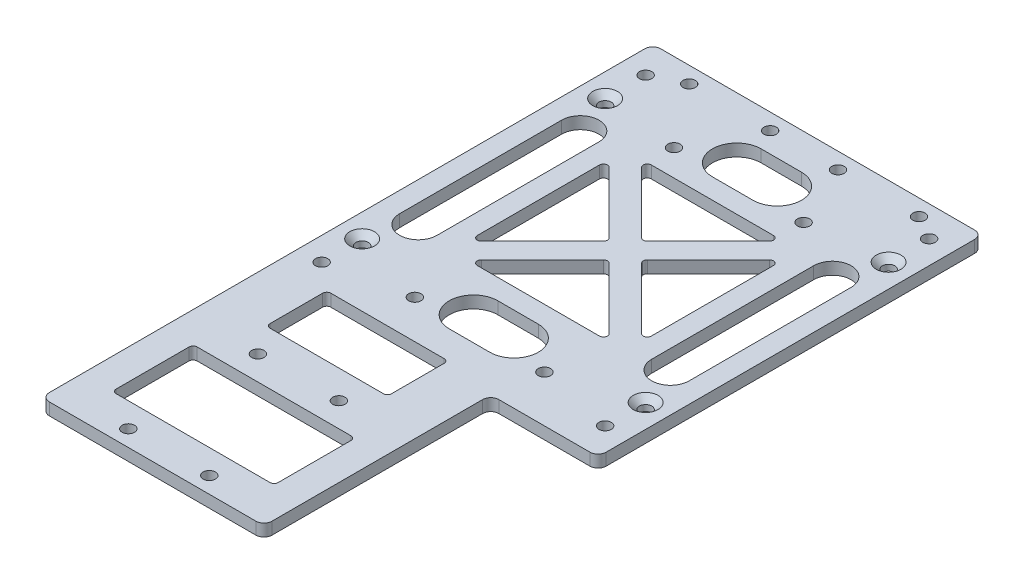
from build123d import *

# Parameters (mm, degrees)
EXTRUDE_1_DEPTH           = 3
SKETCH_2_R                = 1.525
CUT_EXTRUDE_1_DEPTH       = 4
SKETCH_5_W                = 6.5
SKETCH_5_H                = 95
CUT_EXTRUDE_4_DEPTH       = 4
FILLET_3_R                = 2
SKETCH_7_R                = 1.525
CUT_EXTRUDE_6_DEPTH       = 10
SKETCH_10_R               = 1.525
CUT_EXTRUDE_8_DEPTH       = 10
CUT_EXTRUDE_9_DEPTH       = 1
CUT_EXTRUDE_9_DEPTH_BACK  = 4
FILLET_4_R                = 1
SKETCH_15_W               = 40
SKETCH_15_H               = 20
SKETCH_15_W_2             = 30
SKETCH_15_H_2             = 15
CUT_EXTRUDE_10_DEPTH      = 1
CUT_EXTRUDE_10_DEPTH_BACK = 4
FILLET_5_R                = 1
CUT_EXTRUDE_12_DEPTH      = 1
CUT_EXTRUDE_12_DEPTH_BACK = 4
SKETCH_19_R               = 1.525
CUT_EXTRUDE_13_DEPTH      = 10
CUT_EXTRUDE_14_DEPTH      = 10
HOLE_WIZARD_1_D           = 3.05
HOLE_WIZARD_1_DEPTH       = 100
HOLE_WIZARD_1_CSINK_D     = 6.1
HOLE_WIZARD_1_CSINK_ANGLE = 90


with BuildPart() as part:
    # 草图1 → 凸台-拉伸1 (new body)
    with BuildSketch(Plane(origin=(0, 0, 0), x_dir=(1, 0, 0), z_dir=(0, 1, 0))):
        Polygon((33, -55), (33, 0), (33, 40), (-55, 40), (-55, -111), (0, -111), (0, -55), align=None)
    extrude(amount=EXTRUDE_1_DEPTH)

    # 草图2 → 切除-拉伸1 (cut, through all)
    with BuildSketch(Plane(origin=(0, 3, 0), x_dir=(1, 0, 0), z_dir=(0, 1, 0))):
        with Locations((-37.5, -107)):
            Circle(SKETCH_2_R)
        with Locations((-17.5, -107)):
            Circle(SKETCH_2_R)
        with Locations((-37.5, -75)):
            Circle(SKETCH_2_R)
        with Locations((-17.5, -75)):
            Circle(SKETCH_2_R)
        with Locations((-42, 36)):
            Circle(SKETCH_2_R)
        with Locations((-22, 36)):
            Circle(SKETCH_2_R)
        with Locations((-5.25, 36)):
            Circle(SKETCH_2_R)
        with Locations((14.75, 36)):
            Circle(SKETCH_2_R)
    extrude(amount=-CUT_EXTRUDE_1_DEPTH, mode=Mode.SUBTRACT)

    # 草图5 → 切除-拉伸4 (cut, through all)
    with BuildSketch(Plane(origin=(0, 3, 0), x_dir=(1, 0, 0), z_dir=(0, 1, 0))):
        with Locations((29.75, -7.5)):
            Rectangle(SKETCH_5_W, SKETCH_5_H)
    extrude(amount=-CUT_EXTRUDE_4_DEPTH, mode=Mode.SUBTRACT)

    # 圆角3
    fillet_3_edges = [part.edges().sort_by_distance(p)[0] for p in [
        (0, 1.5, 111),
        (-55, 1.5, 111),
        (-55, 1.5, -40),
        (0, 1.5, 55),
        (26.5, 1.5, 55),
        (26.5, 1.5, -40),
    ]]
    fillet(fillet_3_edges, radius=FILLET_3_R)

    # 草图7 → 切除-拉伸6 (cut)
    with BuildSketch(Plane.XZ):
        with Locations((-49.25, 47.5)):
            Circle(SKETCH_7_R)
        with Locations((-49.25, -32.5)):
            Circle(SKETCH_7_R)
        with Locations((20.75, -32.5)):
            Circle(SKETCH_7_R)
        with Locations((20.75, 47.5)):
            Circle(SKETCH_7_R)
    extrude(amount=-CUT_EXTRUDE_6_DEPTH, mode=Mode.SUBTRACT)

    # 草图10 → 切除-拉伸8 (cut)
    with BuildSketch(Plane.XZ):
        with Locations((-30.25, 43.5)):
            Circle(SKETCH_10_R)
        with Locations((1.75, 43.5)):
            Circle(SKETCH_10_R)
        with Locations((-30.25028, -20.4998432)):
            Circle(SKETCH_10_R)
        with Locations((1.75, -20.5)):
            Circle(SKETCH_10_R)
    extrude(amount=-CUT_EXTRUDE_8_DEPTH, mode=Mode.SUBTRACT)

    # 草图14 → 切除-拉伸9 (cut, two sides)
    with BuildSketch(Plane(origin=(0, 3, 0), x_dir=(1, 0, 0), z_dir=(0, 1, 0))) as cut_extrude_9_sk:
        Polygon((-10.25, -7.5), (7.25, 10), (7.25, -25), align=None)
        Polygon((-31.75, 14), (3.25, 14), (-14.25, -3.5), align=None)
        Polygon((-14.25, -11.5), (3.25, -29), (-31.75, -29), align=None)
        Polygon((-18.25, -7.5), (-35.75, -25), (-35.75, 10), align=None)
    extrude(amount=CUT_EXTRUDE_9_DEPTH, mode=Mode.SUBTRACT)
    extrude(cut_extrude_9_sk.sketch, amount=-CUT_EXTRUDE_9_DEPTH_BACK, mode=Mode.SUBTRACT)

    # 圆角4
    fillet_4_edges = [part.edges().sort_by_distance(p)[0] for p in [
        (3.25, 1.5, 29),
        (-31.75, 1.5, 29),
        (-14.25, 1.5, 11.5),
        (7.25, 1.5, -10),
        (7.25, 1.5, 25),
        (-10.25, 1.5, 7.5),
        (-35.75, 1.5, 25),
        (-35.75, 1.5, -10),
        (-18.25, 1.5, 7.5),
        (-14.25, 1.5, 3.5),
        (-31.75, 1.5, -14),
        (3.25, 1.5, -14),
    ]]
    fillet(fillet_4_edges, radius=FILLET_4_R)

    # 草图15 → 切除-拉伸10 (cut, two sides)
    with BuildSketch(Plane(origin=(0, 3, 0), x_dir=(1, 0, 0), z_dir=(0, 1, 0))) as cut_extrude_10_sk:
        with Locations((-27.5, -91)):
            Rectangle(SKETCH_15_W, SKETCH_15_H)
        with Locations((-27.5, -60.5)):
            Rectangle(SKETCH_15_W_2, SKETCH_15_H_2)
    extrude(amount=CUT_EXTRUDE_10_DEPTH, mode=Mode.SUBTRACT)
    extrude(cut_extrude_10_sk.sketch, amount=-CUT_EXTRUDE_10_DEPTH_BACK, mode=Mode.SUBTRACT)

    # 圆角5
    fillet_5_edges = [part.edges().sort_by_distance(p)[0] for p in [
        (-7.5, 1.5, 81),
        (-7.5, 1.5, 101),
        (-47.5, 1.5, 101),
        (-47.5, 1.5, 81),
        (-12.5, 1.5, 53),
        (-12.5, 1.5, 68),
        (-42.5, 1.5, 68),
        (-42.5, 1.5, 53),
    ]]
    fillet(fillet_5_edges, radius=FILLET_5_R)

    # 草图17 → 切除-拉伸12 (cut, two sides)
    with BuildSketch(Plane(origin=(0, 3, 0), x_dir=(1, 0, 0), z_dir=(0, 1, 0))) as cut_extrude_12_sk:
        with BuildLine():
            Line((-19.25, 31), (-9.25, 31))
            ThreePointArc((-9.25, 31), (-3.25, 25), (-9.25, 19))
            Line((-9.25, 19), (-19.25, 19))
            ThreePointArc((-19.25, 19), (-25.25, 25), (-19.25, 31))
        make_face()
        with BuildLine():
            Line((-19.25, -46), (-9.25, -46))
            ThreePointArc((-9.25, -46), (-3.25, -40), (-9.25, -34))
            Line((-9.25, -34), (-19.25, -34))
            ThreePointArc((-19.25, -34), (-25.25, -40), (-19.25, -46))
        make_face()
    extrude(amount=CUT_EXTRUDE_12_DEPTH, mode=Mode.SUBTRACT)
    extrude(cut_extrude_12_sk.sketch, amount=-CUT_EXTRUDE_12_DEPTH_BACK, mode=Mode.SUBTRACT)

    # 草图19 → 切除-拉伸13 (cut)
    with BuildSketch(Plane(origin=(0, 3, 0), x_dir=(1, 0, 0), z_dir=(0, 1, 0))):
        with Locations((-49.25, -37.5)):
            Circle(SKETCH_19_R)
        with Locations((20.75, 22.5)):
            Circle(SKETCH_19_R)
        with Locations((-49.25, 22.5)):
            Circle(SKETCH_19_R)
        with Locations((20.75, -37.5)):
            Circle(SKETCH_19_R)
    extrude(amount=-CUT_EXTRUDE_13_DEPTH, mode=Mode.SUBTRACT)

    # 草图16 → 切除-拉伸14 (cut)
    with BuildSketch(Plane(origin=(0, 3, 0), x_dir=(1, 0, 0), z_dir=(0, 1, 0))):
        with BuildLine():
            Line((-50, -27.5), (-50, 12.5))
            ThreePointArc((-50, 12.5), (-45.375, 17.125), (-40.75, 12.5))
            Line((-40.75, 12.5), (-40.75, -27.5))
            ThreePointArc((-40.75, -27.5), (-45.375, -32.125), (-50, -27.5))
        make_face()
        with BuildLine():
            Line((12.25, -27.5), (12.25, 12.5))
            ThreePointArc((12.25, 12.5), (16.875, 17.125), (21.5, 12.5))
            Line((21.5, 12.5), (21.5, -27.5))
            ThreePointArc((21.5, -27.5), (16.875, -32.125), (12.25, -27.5))
        make_face()
    extrude(amount=-CUT_EXTRUDE_14_DEPTH, mode=Mode.SUBTRACT)

    # 孔1
    with Locations(Plane(origin=(20.75, 3, 37.5), x_dir=(0, 0, 1), z_dir=(0, 1, 0))):
        with Locations((0, 0), (-60, -70), (0, -70), (-60, 0)):
            CounterSinkHole(HOLE_WIZARD_1_D / 2, HOLE_WIZARD_1_CSINK_D / 2, depth=HOLE_WIZARD_1_DEPTH, counter_sink_angle=HOLE_WIZARD_1_CSINK_ANGLE)


solid = part.part
